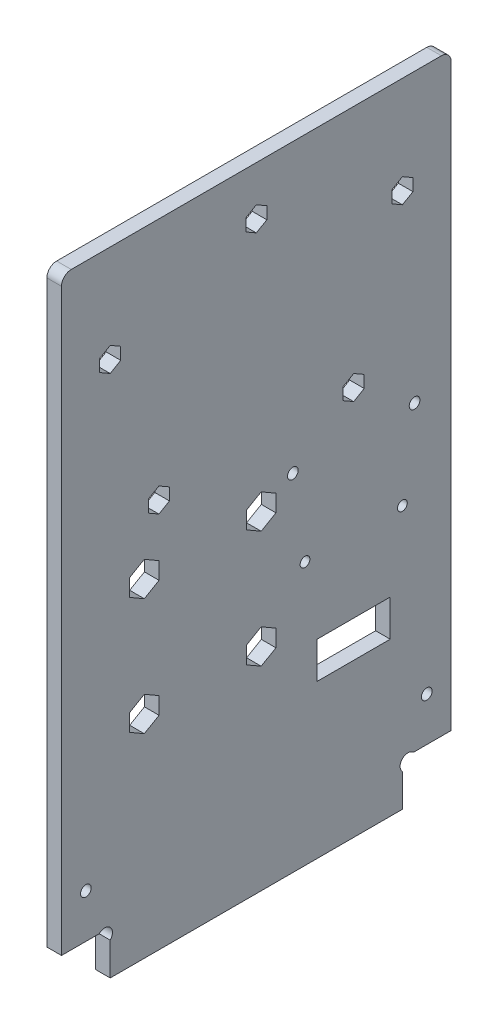
from build123d import *

# Parameters (mm, degrees)
EXTRUSION1_DEPTH        = 3
ESQUISSE2_R             = 1
ESQUISSE2_R_2           = 1.5
ENL_V_MAT_EXTRU_1_DEPTH = 4
ESQUISSE3_W             = 15
ESQUISSE3_H             = 7.5
ENL_V_MAT_EXTRU_2_DEPTH = 4
ESQUISSE4_R             = 1.1
ENL_V_MAT_EXTRU_3_DEPTH = 4
ENL_V_MAT_EXTRU_4_DEPTH = 4
CONG_1_R                = 2
ESQUISSE6_R             = 1.1
ENL_V_MAT_EXTRU_5_DEPTH = 4


with BuildPart() as part:
    # Esquisse1 → Extrusion1 (new body)
    with BuildSketch(Plane(origin=(0, 0, 0), x_dir=(0, 0, -1), z_dir=(1, 0, 0))):
        with BuildLine():
            Line((10, 6.7372583), (10, 0))
            Line((10, 0), (70, 0))
            Line((70, 0), (70, 6.7372583))
            ThreePointArc((70, 6.7372583), (70, 9), (72.2627417, 9))
            Line((72.2627417, 9), (80, 9))
            Line((80, 9), (80, 130))
            Line((80, 130), (0, 130))
            Line((0, 130), (0, 9))
            Line((0, 9), (7.7372583, 9))
            ThreePointArc((7.7372583, 9), (10, 9), (10, 6.7372583))
        make_face()
    extrude(amount=EXTRUSION1_DEPTH)

    # Esquisse2 → Enlèv. mat.-Extru.1 (cut, through all)
    with BuildSketch(Plane(origin=(3, 0, 0), x_dir=(0, 0, -1), z_dir=(1, 0, 0))):
        with Locations((60, 80)):
            Circle(ESQUISSE2_R)
        with Locations((10, 110)):
            Circle(ESQUISSE2_R)
        with Locations(Location((20, 80, 0), (0, 0, 180))):  # turned: the seam where the file's is
            Circle(ESQUISSE2_R)
        with Locations((70, 110)):
            Circle(ESQUISSE2_R)
        with Locations((17, 67.45)):
            Circle(ESQUISSE2_R_2)
        with Locations((17, 43.45)):
            Circle(ESQUISSE2_R_2)
        with Locations((41, 43.45)):
            Circle(ESQUISSE2_R_2)
        with Locations((41, 67.45)):
            Circle(ESQUISSE2_R_2)
        with Locations((40, 120)):
            Circle(ESQUISSE2_R)
        with Locations((70, 54)):
            Circle(ESQUISSE2_R)
        with Locations((50, 54)):
            Circle(ESQUISSE2_R)
    extrude(amount=-ENL_V_MAT_EXTRU_1_DEPTH, mode=Mode.SUBTRACT)

    # Esquisse3 → Enlèv. mat.-Extru.2 (cut, through all)
    with BuildSketch(Plane.ZY):
        with Locations((-60, 35.25)):
            Rectangle(ESQUISSE3_W, ESQUISSE3_H)
    extrude(amount=-ENL_V_MAT_EXTRU_2_DEPTH, mode=Mode.SUBTRACT)

    # Esquisse4 → Enlèv. mat.-Extru.3 (cut, through all)
    with BuildSketch(Plane(origin=(3, 0, 0), x_dir=(0, 0, -1), z_dir=(1, 0, 0))):
        with Locations((75, 18)):
            Circle(ESQUISSE4_R)
        with Locations((5, 18)):
            Circle(ESQUISSE4_R)
    extrude(amount=-ENL_V_MAT_EXTRU_3_DEPTH, mode=Mode.SUBTRACT)

    # Esquisse5 → Enlèv. mat.-Extru.4 (cut, through all)
    with BuildSketch(Plane(origin=(3, 0, 0), x_dir=(0, 0, -1), z_dir=(1, 0, 0))):
        Polygon((12.165063509, 111.25), (10, 112.5), (7.834936491, 111.25), (7.834936491, 108.75), (10, 107.5), (12.165063509, 108.75), align=None)
        Polygon((42.165063509, 118.75), (42.165063509, 121.25), (40, 122.5), (37.834936491, 121.25), (37.834936491, 118.75), (40, 117.5), align=None)
        Polygon((70, 107.5), (72.165063509, 108.75), (72.165063509, 111.25), (70, 112.5), (67.834936491, 111.25), (67.834936491, 108.75), align=None)
        Polygon((62.165063509, 78.75), (62.165063509, 81.25), (60, 82.5), (57.834936491, 81.25), (57.834936491, 78.75), (60, 77.5), align=None)
        Polygon((22.165063509, 78.75), (22.165063509, 81.25), (20, 82.5), (17.834936491, 81.25), (17.834936491, 78.75), (20, 77.5), align=None)
        Polygon((44.031088913, 65.7), (44.031088913, 69.2), (41, 70.95), (37.968911087, 69.2), (37.968911087, 65.7), (41, 63.95), align=None)
        Polygon((44.031088913, 41.7), (44.031088913, 45.2), (41, 46.95), (37.968911087, 45.2), (37.968911087, 41.7), (41, 39.95), align=None)
        Polygon((20.031088913, 41.7), (20.031088913, 45.2), (17, 46.95), (13.968911087, 45.2), (13.968911087, 41.7), (17, 39.95), align=None)
        Polygon((20.031088913, 65.7), (20.031088913, 69.2), (17, 70.95), (13.968911087, 69.2), (13.968911087, 65.7), (17, 63.95), align=None)
    extrude(amount=-ENL_V_MAT_EXTRU_4_DEPTH, mode=Mode.SUBTRACT)

    # Congé1
    cong_1_edges = [part.edges().sort_by_distance(p)[0] for p in [
        (1.5, 130, 0),
        (1.5, 130, -80),
    ]]
    fillet(cong_1_edges, radius=CONG_1_R)

    # Esquisse6 → Enlèv. mat.-Extru.5 (cut, through all)
    with BuildSketch(Plane.ZY):
        with Locations((-72.5, 71)):
            Circle(ESQUISSE6_R)
        with Locations((-47.5, 71)):
            Circle(ESQUISSE6_R)
    extrude(amount=-ENL_V_MAT_EXTRU_5_DEPTH, mode=Mode.SUBTRACT)


solid = part.part
